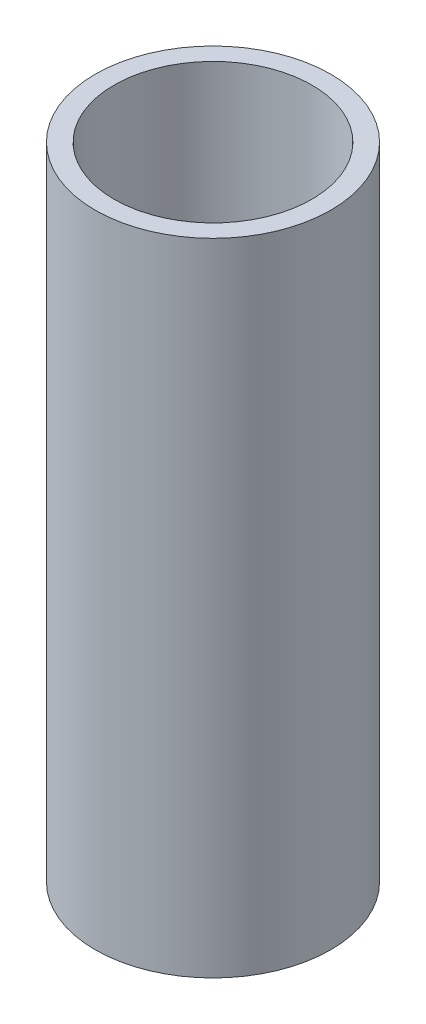
from build123d import *

# Parameters (mm, degrees)
SKETCH_1_R      = 5
SKETCH_1_R_2    = 4.2
EXTRUDE_1_DEPTH = 27.19


with BuildPart() as part:
    # 草图1 → 凸台-拉伸1 (new body)
    with BuildSketch(Plane(origin=(0, 0, 0), x_dir=(1, 0, 0), z_dir=(0, 1, 0))):
        Circle(SKETCH_1_R)
        Circle(SKETCH_1_R_2, mode=Mode.SUBTRACT)
    extrude(amount=EXTRUDE_1_DEPTH)


solid = part.part
